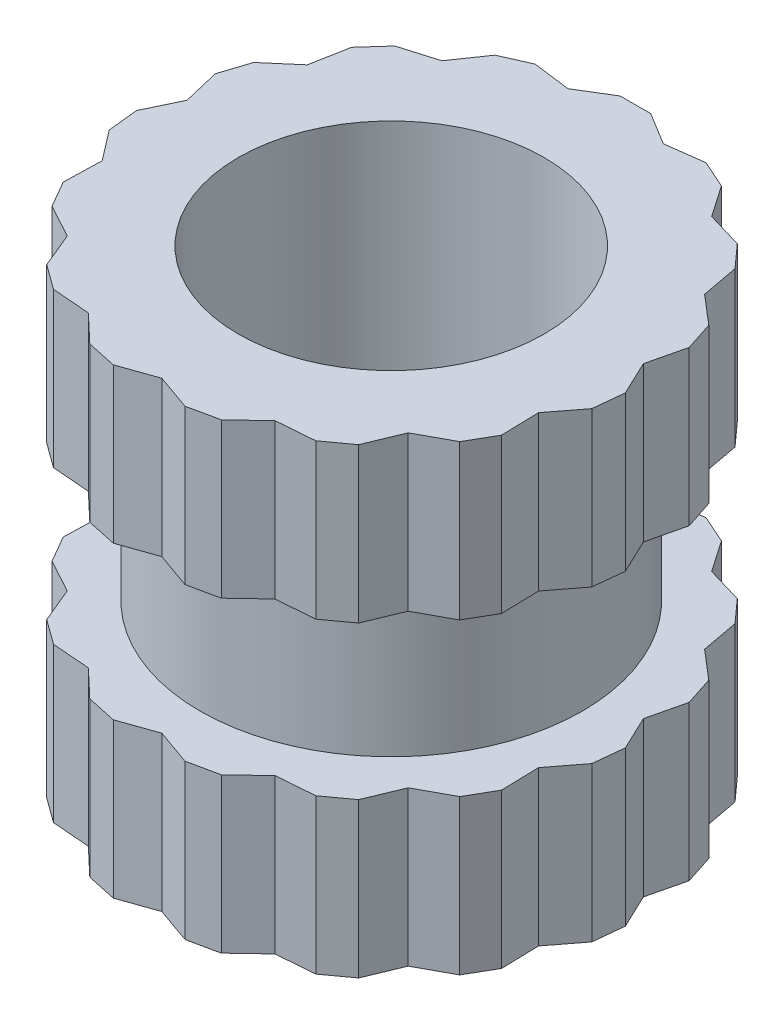
from build123d import *

# Parameters (mm, degrees)
SKETCH1_R           = 1.25
SKETCH1_R_2         = 1
BOSS_EXTRUDE1_DEPTH = 0.5
SKETCH2_R           = 1
BOSS_EXTRUDE2_DEPTH = 1.01


with BuildPart() as part:
    # Sketch1 → Boss-Extrude1 (new body)
    with BuildSketch(Plane(origin=(0, 0, 0), x_dir=(1, 0, 0), z_dir=(0, 1, 0))):
        Circle(SKETCH1_R)
        Circle(SKETCH1_R_2, mode=Mode.SUBTRACT)
    boss_extrude1 = extrude(amount=BOSS_EXTRUDE1_DEPTH)

    # Sketch2 → Boss-Extrude2 (add)
    with BuildSketch(Plane(origin=(0, 0.5, 0), x_dir=(1, 0, 0), z_dir=(0, 1, 0))):
        Polygon((-0.740860879, 1.418141445), (-0.881677878, 1.213525492), (-1.11979406, 1.142830374), (-1.253620181, 0.994201408), (-1.299038106, 0.75), (-1.487813767, 0.58856622), (-1.549617166, 0.398354916), (-1.491782843, 0.156792695), (-1.598576957, -0.067466381), (-1.577671264, -0.26637076), (-1.426584774, -0.463525492), (-1.432931669, -0.711833431), (-1.332931669, -0.885038512), (-1.114717238, -1.00369591), (-1.019519477, -1.233118014), (-0.857716078, -1.350675064), (-0.610104965, -1.370318186), (-0.429823106, -1.54118529), (-0.234193585, -1.582767628), (0, -1.5), (0.234193585, -1.582767628), (0.429823106, -1.54118529), (0.610104965, -1.370318186), (0.857716078, -1.350675064), (1.019519477, -1.233118014), (1.114717238, -1.00369591), (1.332931669, -0.885038512), (1.432931669, -0.711833431), (1.426584774, -0.463525492), (1.577671264, -0.26637076), (1.598576957, -0.067466381), (1.491782843, 0.156792695), (1.549617166, 0.398354916), (1.487813767, 0.58856622), (1.299038106, 0.75), (1.253620181, 0.994201408), (1.11979406, 1.142830374), (0.881677878, 1.213525492), (0.740860879, 1.418141445), (0.558151787, 1.499488774), (0.311867536, 1.467221401), (0.1, 1.596871942), (-0.1, 1.596871942), (-0.311867536, 1.467221401), (-0.558151787, 1.499488774), align=None)
        Circle(SKETCH2_R, mode=Mode.SUBTRACT)
    boss_extrude2 = extrude(amount=BOSS_EXTRUDE2_DEPTH)

    # Mirror1: Boss-Extrude1, Boss-Extrude2 across plane
    add(boss_extrude1.mirror(Plane.ZX))
    add(boss_extrude2.mirror(Plane.ZX))


solid = part.part
